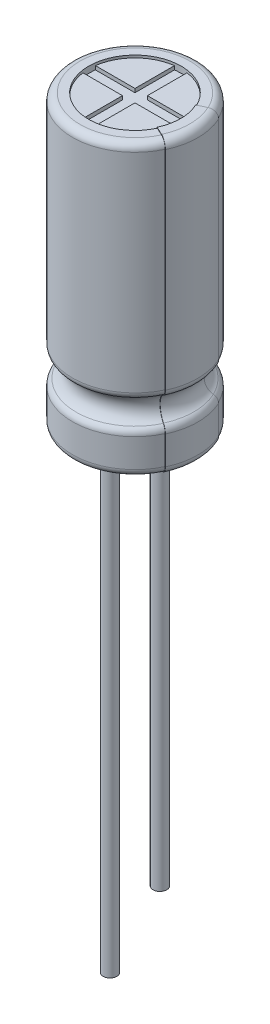
from build123d import *

# Parameters (mm, degrees)
BOSS_EXTRUDE1_DEPTH      = 0.15
BOSS_EXTRUDE1_2_DEPTH    = 0.15
BOSS_EXTRUDE1_3_DEPTH    = 0.15
BOSS_EXTRUDE1_4_DEPTH    = 0.15
SKETCH3_R                = 1.5
SKETCH3_RX               = 1.4
SKETCH3_RY               = 0.8
BOSS_EXTRUDE2_DEPTH      = 0.6
REVOLVE3_ANGLE           = 25
REVOLVE3_OTHER_WAY_ANGLE = 25
SKETCH7_R                = 0.275
BOSS_EXTRUDE3_DEPTH      = 19.6
SKETCH7_4_R              = 0.275
BOSS_EXTRUDE4_DEPTH      = 15.6


with BuildPart() as part:
    # Sketch1 → Revolve1 (revolve)
    with BuildSketch(Plane.XY, mode=Mode.PRIVATE) as revolve1_sk:
        with BuildLine():
            Line((0, 0.6), (1.9, 0.6))
            Line((1.9, 0.6), (1.9, 0.4))
            Line((1.9, 0.4), (2.2, 0.4))
            ThreePointArc((2.2, 0.4), (2.412132034, 0.487867966), (2.5, 0.7))
            Line((2.5, 0.7), (2.5, 1.841493624))
            ThreePointArc((2.5, 1.841493624), (2.460692429, 1.989950545), (2.353070284, 2.09950426))
            ThreePointArc((2.353070284, 2.09950426), (2.0680522, 2.6), (2.353070284, 3.10049574))
            ThreePointArc((2.353070284, 3.10049574), (2.460692429, 3.210049455), (2.5, 3.358506376))
            Line((2.5, 3.358506376), (2.5, 11.7))
            ThreePointArc((2.5, 11.7), (2.412132034, 11.912132034), (2.2, 12))
            Line((2.2, 12), (1.85, 12))
            Line((1.85, 12), (1.85, 11.75))
            Line((1.85, 11.75), (0, 11.75))
            Line((0, 11.75), (0, 0.6))
        make_face()
    revolve(revolve1_sk.sketch.rotate(Axis((0, 11.75, 0), (0, -1, 0)), 180), axis=Axis((0, 11.75, 0), (0, -1, 0)))



with BuildPart() as body_2:
    # Sketch2 → Boss-Extrude1 (new body)
    with BuildSketch(Plane(origin=(0, 11.75, 0), x_dir=(1, 0, 0), z_dir=(0, 1, 0))):
        with BuildLine():
            Line((-0.25, 0.25), (-0.25, 1.833030278))
            ThreePointArc((-0.25, 1.833030278), (-1.308147545, 1.308147545), (-1.833030278, 0.25))
            Line((-1.833030278, 0.25), (-0.25, 0.25))
        make_face()
    extrude(amount=BOSS_EXTRUDE1_DEPTH)


with BuildPart() as body_3:
    # Sketch2 → Boss-Extrude1 2 (new body)
    with BuildSketch(Plane(origin=(0, 11.75, 0), x_dir=(1, 0, 0), z_dir=(0, 1, 0))):
        with BuildLine():
            Line((0.25, -1.833030278), (0.25, -0.25))
            Line((0.25, -0.25), (1.833030278, -0.25))
            ThreePointArc((1.833030278, -0.25), (1.308147545, -1.308147545), (0.25, -1.833030278))
        make_face()
    extrude(amount=BOSS_EXTRUDE1_2_DEPTH)


with BuildPart() as body_4:
    # Sketch2 → Boss-Extrude1 3 (new body)
    with BuildSketch(Plane(origin=(0, 11.75, 0), x_dir=(1, 0, 0), z_dir=(0, 1, 0))):
        with BuildLine():
            Line((-0.25, -1.833030278), (-0.25, -0.25))
            Line((-0.25, -0.25), (-1.833030278, -0.25))
            ThreePointArc((-1.833030278, -0.25), (-1.308147545, -1.308147545), (-0.25, -1.833030278))
        make_face()
    extrude(amount=BOSS_EXTRUDE1_3_DEPTH)


with BuildPart() as body_5:
    # Sketch2 → Boss-Extrude1 4 (new body)
    with BuildSketch(Plane(origin=(0, 11.75, 0), x_dir=(1, 0, 0), z_dir=(0, 1, 0))):
        with BuildLine():
            Line((0.25, 0.25), (0.25, 1.833030278))
            ThreePointArc((0.25, 1.833030278), (1.308147545, 1.308147545), (1.833030278, 0.25))
            Line((1.833030278, 0.25), (0.25, 0.25))
        make_face()
    extrude(amount=BOSS_EXTRUDE1_4_DEPTH)


with BuildPart() as body_6:
    # Sketch3 → Boss-Extrude2 (new body)
    with BuildSketch(Plane.XZ.offset(-0.6)):
        Circle(SKETCH3_R)
        with Locations(Location((0, 0), (0, 0, 180))):
            Ellipse(SKETCH3_RX, SKETCH3_RY, mode=Mode.SUBTRACT)
    extrude(amount=BOSS_EXTRUDE2_DEPTH)


with BuildPart() as body_7:
    # Sketch5 → Revolve3 (revolve)
    with BuildSketch(Plane.XY):
        with BuildLine():
            Line((2.52, 11.7), (2.52, 3.358506376))
            ThreePointArc((2.52, 3.358506376), (2.478071924, 3.200152326), (2.363274969, 3.083295031))
            ThreePointArc((2.363274969, 3.083295031), (2.0880522, 2.6), (2.363274969, 2.116704969))
            ThreePointArc((2.363274969, 2.116704969), (2.478071924, 1.999847674), (2.52, 1.841493624))
            Line((2.52, 1.841493624), (2.52, 0.7))
            ThreePointArc((2.52, 0.7), (2.42627417, 0.47372583), (2.2, 0.38))
            Line((2.2, 0.38), (1.880086021, 0.38))
            Line((1.880086021, 0.38), (1.829913607, 12.02))
            Line((1.829913607, 12.02), (2.2, 12.02))
            ThreePointArc((2.2, 12.02), (2.42627417, 11.92627417), (2.52, 11.7))
        make_face()
        with BuildLine():
            Line((1.85, 12), (2.2, 12))
            ThreePointArc((2.2, 12), (2.412132034, 11.912132034), (2.5, 11.7))
            Line((2.5, 11.7), (2.5, 3.358506376))
            ThreePointArc((2.5, 3.358506376), (2.460692429, 3.210049455), (2.353070284, 3.10049574))
            ThreePointArc((2.353070284, 3.10049574), (2.0680522, 2.6), (2.353070284, 2.09950426))
            ThreePointArc((2.353070284, 2.09950426), (2.460692429, 1.989950545), (2.5, 1.841493624))
            Line((2.5, 1.841493624), (2.5, 0.7))
            ThreePointArc((2.5, 0.7), (2.412132034, 0.487867966), (2.2, 0.4))
            Line((2.2, 0.4), (1.9, 0.4))
            Line((1.9, 0.4), (1.85, 12))
        make_face(mode=Mode.SUBTRACT)
    revolve(axis=Axis((0, 0, 0), (0, 1, 0)), revolution_arc=REVOLVE3_ANGLE)

    # Sketch5 → Revolve3 other way (revolve)
    with BuildSketch(Plane.XY):
        with BuildLine():
            Line((2.52, 11.7), (2.52, 3.358506376))
            ThreePointArc((2.52, 3.358506376), (2.478071924, 3.200152326), (2.363274969, 3.083295031))
            ThreePointArc((2.363274969, 3.083295031), (2.0880522, 2.6), (2.363274969, 2.116704969))
            ThreePointArc((2.363274969, 2.116704969), (2.478071924, 1.999847674), (2.52, 1.841493624))
            Line((2.52, 1.841493624), (2.52, 0.7))
            ThreePointArc((2.52, 0.7), (2.42627417, 0.47372583), (2.2, 0.38))
            Line((2.2, 0.38), (1.880086021, 0.38))
            Line((1.880086021, 0.38), (1.829913607, 12.02))
            Line((1.829913607, 12.02), (2.2, 12.02))
            ThreePointArc((2.2, 12.02), (2.42627417, 11.92627417), (2.52, 11.7))
        make_face()
        with BuildLine():
            Line((1.85, 12), (2.2, 12))
            ThreePointArc((2.2, 12), (2.412132034, 11.912132034), (2.5, 11.7))
            Line((2.5, 11.7), (2.5, 3.358506376))
            ThreePointArc((2.5, 3.358506376), (2.460692429, 3.210049455), (2.353070284, 3.10049574))
            ThreePointArc((2.353070284, 3.10049574), (2.0680522, 2.6), (2.353070284, 2.09950426))
            ThreePointArc((2.353070284, 2.09950426), (2.460692429, 1.989950545), (2.5, 1.841493624))
            Line((2.5, 1.841493624), (2.5, 0.7))
            ThreePointArc((2.5, 0.7), (2.412132034, 0.487867966), (2.2, 0.4))
            Line((2.2, 0.4), (1.9, 0.4))
            Line((1.9, 0.4), (1.85, 12))
        make_face(mode=Mode.SUBTRACT)
    revolve(axis=Axis((0, 0, 0), (0, -1, 0)), revolution_arc=REVOLVE3_OTHER_WAY_ANGLE)


with BuildPart() as part_1:
    add(part.part)

    add(body_6.part)  # Boss-Extrude3 merges body 6
    # Sketch7 → Boss-Extrude3 (add)
    with BuildSketch(Plane.XZ.offset(-0.6)):
        with Locations(Location((-1, 0, 0), (0, 0, 180))):
            Circle(SKETCH7_R)
    extrude(amount=BOSS_EXTRUDE3_DEPTH)

    # Sketch7_4 → Boss-Extrude4 (add)
    with BuildSketch(Plane.XZ.offset(-0.6)):
        with Locations(Location((1, 0, 0), (0, 0, 180))):
            Circle(SKETCH7_4_R)
    extrude(amount=BOSS_EXTRUDE4_DEPTH)


solid = Compound([body_2.part, body_3.part, body_4.part, body_5.part, body_7.part, part_1.part])
